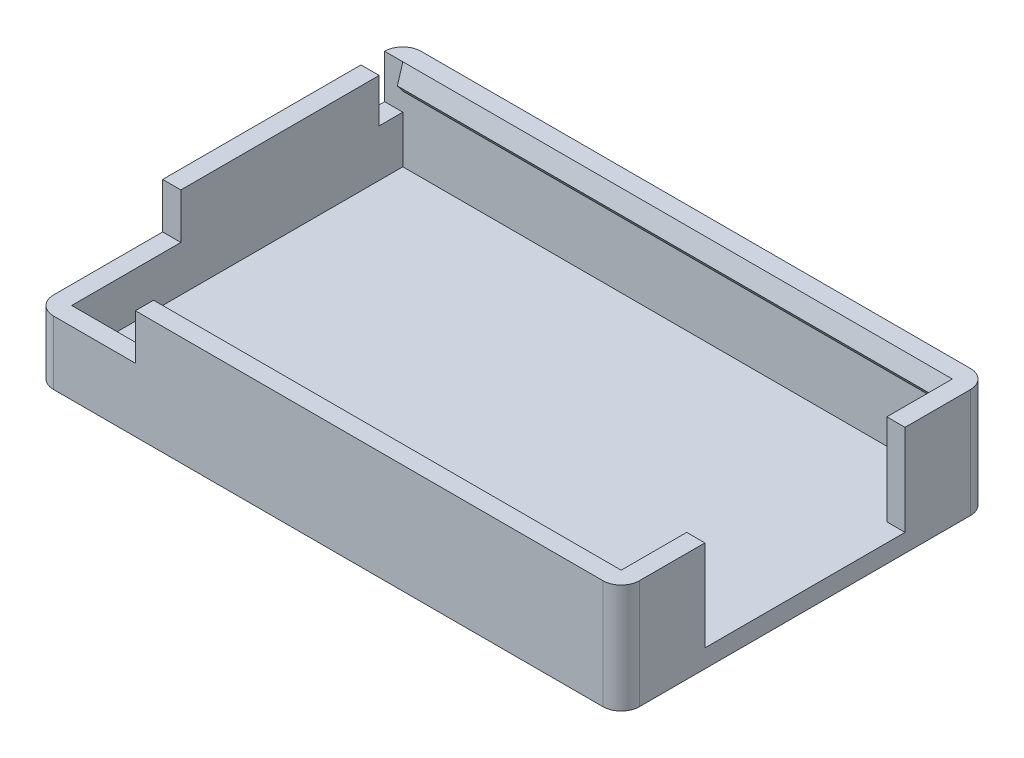
from build123d import *

# Parameters (mm, degrees)
SKETCH1_W                       = 32.2
SKETCH1_H                       = 20.2
BOSS_EXTRUDE1_DEPTH             = 1
BOSS_EXTRUDE2_DEPTH             = 2.5
BOSS_EXTRUDE3_DEPTH             = 2.5
BOSS_EXTRUDE4_REACH             = 18.1
BOSS_EXTRUDE4_DIRECTION_2_REACH = 18.1
BOSS_EXTRUDE5_DEPTH             = 4.5
FILLET1_R                       = 1
SKETCH6_W                       = 1.3
SKETCH6_H                       = 2.4
CUT_EXTRUDE1_DEPTH              = 1


with BuildPart() as part:
    # Sketch1 → Boss-Extrude1 (new body)
    with BuildSketch(Plane(origin=(0, 0, 0), x_dir=(1, 0, 0), z_dir=(0, 1, 0))):
        Rectangle(SKETCH1_W, SKETCH1_H)
    extrude(amount=BOSS_EXTRUDE1_DEPTH)

    # Sketch2 → Boss-Extrude2 (add)
    with BuildSketch(Plane(origin=(0, 1, 0), x_dir=(1, 0, 0), z_dir=(0, 1, 0))):
        Polygon((-16.1, -10.1), (16.1, -10.1), (16.1, -5.5), (15.1, -5.5), (15.1, -9.1), (-15.1, -9.1), (-15.1, 9.1), (15.1, 9.1), (15.1, 5.5), (16.1, 5.5), (16.1, 10.1), (-16.1, 10.1), align=None)
    extrude(amount=BOSS_EXTRUDE2_DEPTH)

    # Sketch3 → Boss-Extrude3 (add)
    with BuildSketch(Plane(origin=(0, 3.5, 0), x_dir=(1, 0, 0), z_dir=(0, 1, 0))):
        Polygon((-10.6, -9.1), (-10.6, -10.1), (16.1, -10.1), (16.1, -5.5), (15.1, -5.5), (15.1, -9.1), align=None)
        Polygon((-16.1, -3.1), (-15.1, -3.1), (-15.1, 9.1), (15.1, 9.1), (15.1, 5.5), (16.1, 5.5), (16.1, 10.1), (-16.1, 10.1), align=None)
    extrude(amount=BOSS_EXTRUDE3_DEPTH)

    # Boss-Extrude4: up to this face of the body (flat: up to its plane)
    boss_extrude4_end = Plane(part.part.faces().sort_by_distance((15.1, 3.5, -7.3))[0])
    # Sketch4 → Boss-Extrude4 (add, up to the picked face)
    with BuildSketch(Plane(origin=(0, 0, 0), x_dir=(0, 0, -1), z_dir=(1, 0, 0)), mode=Mode.PRIVATE) as boss_extrude4_sk1:
        Polygon((-9.1, 6), (-8.8, 5), (-9.1, 4.6), (-9.1, 5), align=None)
    boss_extrude4_tool1 = split(extrude(boss_extrude4_sk1.sketch, amount=BOSS_EXTRUDE4_REACH, mode=Mode.PRIVATE), bisect_by=boss_extrude4_end, keep=Keep.BOTH, mode=Mode.PRIVATE)
    add(boss_extrude4_tool1.solids().sort_by_distance((0, 5.2, 9))[0])
    # Sketch4 → Boss-Extrude4 (add, up to the picked face)
    with BuildSketch(Plane(origin=(0, 0, 0), x_dir=(0, 0, -1), z_dir=(1, 0, 0)), mode=Mode.PRIVATE) as boss_extrude4_sk2:
        Polygon((9.1, 4.6), (9.1, 5), (9.1, 6), (8.8, 5), align=None)
    boss_extrude4_tool2 = split(extrude(boss_extrude4_sk2.sketch, amount=BOSS_EXTRUDE4_REACH, mode=Mode.PRIVATE), bisect_by=boss_extrude4_end, keep=Keep.BOTH, mode=Mode.PRIVATE)
    add(boss_extrude4_tool2.solids().sort_by_distance((0, 5.2, -9))[0])

    # Boss-Extrude4 direction 2: up to this face of the body (flat: up to its plane)
    boss_extrude4_direction_2_end = Plane(part.part.faces().sort_by_distance((-10.6, 4.75, 9.6))[0])
    # Sketch4 → Boss-Extrude4 direction 2 (add, up to the picked face)
    with BuildSketch(Plane(origin=(0, 0, 0), x_dir=(0, 0, -1), z_dir=(1, 0, 0)), mode=Mode.PRIVATE) as boss_extrude4_direction_2_sk1:
        Polygon((-9.1, 6), (-8.8, 5), (-9.1, 4.6), (-9.1, 5), align=None)
    boss_extrude4_direction_2_tool1 = split(extrude(boss_extrude4_direction_2_sk1.sketch, amount=-BOSS_EXTRUDE4_DIRECTION_2_REACH, mode=Mode.PRIVATE), bisect_by=boss_extrude4_direction_2_end, keep=Keep.BOTH, mode=Mode.PRIVATE)
    add(boss_extrude4_direction_2_tool1.solids().sort_by_distance((0, 5.2, 9))[0])
    # Sketch4 → Boss-Extrude4 direction 2 (add, up to the picked face)
    with BuildSketch(Plane(origin=(0, 0, 0), x_dir=(0, 0, -1), z_dir=(1, 0, 0)), mode=Mode.PRIVATE) as boss_extrude4_direction_2_sk2:
        Polygon((9.1, 4.6), (9.1, 5), (9.1, 6), (8.8, 5), align=None)
    boss_extrude4_direction_2_tool2 = split(extrude(boss_extrude4_direction_2_sk2.sketch, amount=-BOSS_EXTRUDE4_DIRECTION_2_REACH, mode=Mode.PRIVATE), bisect_by=boss_extrude4_direction_2_end, keep=Keep.BOTH, mode=Mode.PRIVATE)
    add(boss_extrude4_direction_2_tool2.solids().sort_by_distance((0, 5.2, -9))[0])

    # Sketch5 → Boss-Extrude5 (add)
    with BuildSketch(Plane.ZY.offset(10.6)):
        Polygon((-9.1, 4.6), (-8.8, 5), (-9.1, 6), align=None)
    extrude(amount=BOSS_EXTRUDE5_DEPTH)

    # Fillet1
    fillet1_edges = [part.edges().sort_by_distance(p)[0] for p in [
        (16.1, 3, 10.1),
        (-16.1, 1.75, 10.1),
        (-16.1, 3, -10.1),
        (16.1, 3, -10.1),
    ]]
    fillet(fillet1_edges, radius=FILLET1_R)

    # Sketch6 → Cut-Extrude1 (cut)
    with BuildSketch(Plane.ZY.offset(15.1)):
        with Locations((-8.45, 4.8)):
            Rectangle(SKETCH6_W, SKETCH6_H)
    extrude(amount=CUT_EXTRUDE1_DEPTH, mode=Mode.SUBTRACT)


solid = part.part
